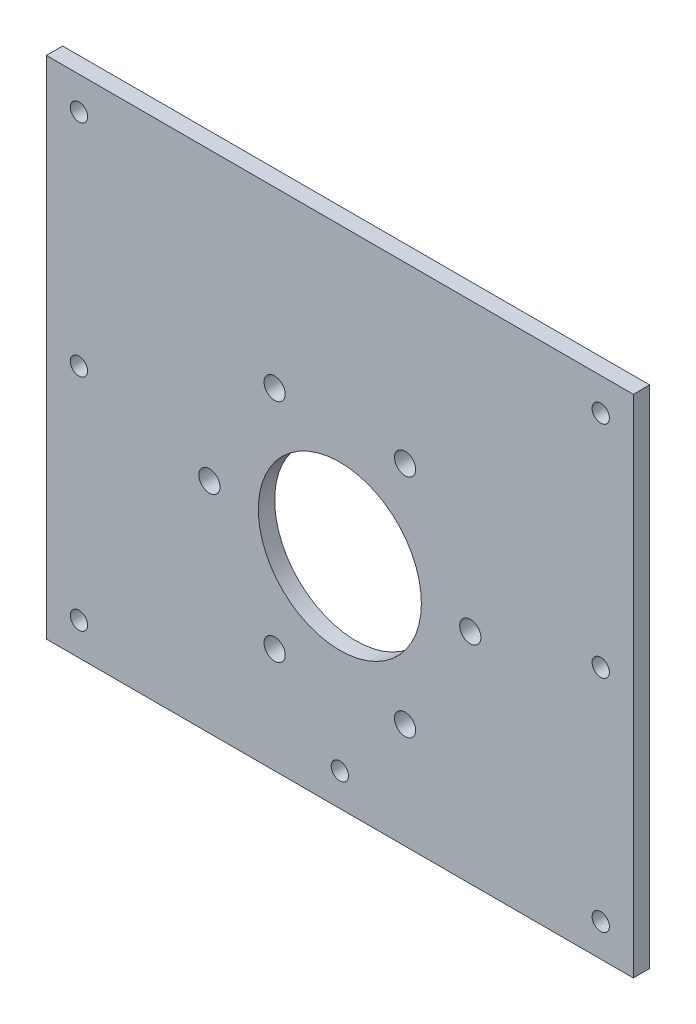
from build123d import *

# Parameters (mm, degrees)
SKETCH1_W           = 180
SKETCH1_H           = 155
BOSS_EXTRUDE1_DEPTH = 5
SKETCH2_R           = 25
CUT_EXTRUDE1_DEPTH  = 6
SKETCH3_R           = 3.25
SKETCH3_R_2         = 2.65
CUT_EXTRUDE2_DEPTH  = 6


with BuildPart() as part:
    # Sketch1 → Boss-Extrude1 (new body)
    with BuildSketch(Plane.XY):
        with Locations((90, 77.5)):
            Rectangle(SKETCH1_W, SKETCH1_H)
    extrude(amount=BOSS_EXTRUDE1_DEPTH)

    # Sketch2 → Cut-Extrude1 (cut, through all)
    with BuildSketch(Plane.XY.offset(5)):
        with Locations((90, 67)):
            Circle(SKETCH2_R)
    extrude(amount=-CUT_EXTRUDE1_DEPTH, mode=Mode.SUBTRACT)

    # Sketch3 → Cut-Extrude2 (cut, through all)
    with BuildSketch(Plane.XY.offset(5)):
        with Locations((110, 101.641016151)):
            Circle(SKETCH3_R)
        with Locations((130, 67)):
            Circle(SKETCH3_R)
        with Locations((110, 32.358983849)):
            Circle(SKETCH3_R)
        with Locations((70, 32.358983849)):
            Circle(SKETCH3_R)
        with Locations((50, 67)):
            Circle(SKETCH3_R)
        with Locations((70, 101.641016151)):
            Circle(SKETCH3_R)
        with Locations((10, 145)):
            Circle(SKETCH3_R_2)
        with Locations((10, 77.5)):
            Circle(SKETCH3_R_2)
        with Locations((10, 10)):
            Circle(SKETCH3_R_2)
        with Locations((170, 10)):
            Circle(SKETCH3_R_2)
        with Locations((170, 77.5)):
            Circle(SKETCH3_R_2)
        with Locations((170, 145)):
            Circle(SKETCH3_R_2)
        with Locations((90, 10)):
            Circle(SKETCH3_R_2)
    extrude(amount=-CUT_EXTRUDE2_DEPTH, mode=Mode.SUBTRACT)


solid = part.part
